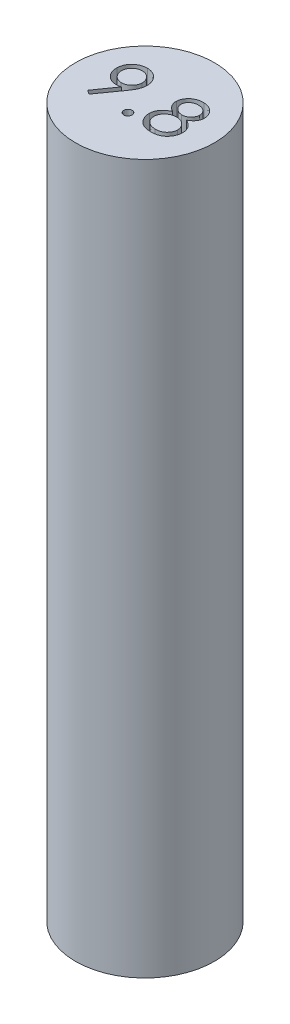
from build123d import *

# Parameters (mm, degrees)
SKETCH1_R           = 4.9
BOSS_EXTRUDE1_DEPTH = 50
CUT_EXTRUDE1_DEPTH  = 3


with BuildPart() as part:
    # Sketch1 → Boss-Extrude1 (new body)
    with BuildSketch(Plane(origin=(0, 0, 0), x_dir=(1, 0, 0), z_dir=(0, 1, 0))):
        Circle(SKETCH1_R)
    extrude(amount=BOSS_EXTRUDE1_DEPTH)

    # Sketch2 → Cut-Extrude1 (cut)
    with BuildSketch(Plane(origin=(0, 50, 0), x_dir=(1, 0, 0), z_dir=(0, 1, 0))):
        with BuildLine():
            Line((-2.497585936, -1.449920869), (-2.778735775, -1.257813497))
            Line((-2.778735775, -1.257813497), (-1.79996975, 0.140924483))
            add(Edge.make_bspline(
                [(-1.79996975, 0.140924483), (-1.831154526, 0.132154323), (-1.891844067, 0.115086476), (-1.9830553, 0.099892479), (-2.070552365, 0.088614887), (-2.128060127, 0.088901517), (-2.156139621, 0.089041471)],
                knots=[0, 0, 0, 0, 9.7102e-05, 0.000188973, 0.000277161, 0.000361308, 0.000361308, 0.000361308, 0.000361308], degree=3))
            add(Edge.make_bspline(
                [(-2.156139621, 0.089041471), (-2.190094119, 0.090939259), (-2.256985081, 0.094677935), (-2.354733317, 0.111790883), (-2.448154149, 0.137987973), (-2.537749058, 0.172862579), (-2.622596718, 0.218357513), (-2.70409283, 0.271705107), (-2.780492641, 0.335419932), (-2.852309599, 0.407025859), (-2.91688194, 0.485644752), (-2.97334181, 0.569004078), (-3.021779134, 0.656136274), (-3.059080726, 0.748188227), (-3.088534655, 0.843835137), (-3.107527163, 0.943763592), (-3.119609821, 1.047642801), (-3.119059029, 1.118254288), (-3.118779846, 1.154045477)],
                knots=[0, 0, 0, 0, 0.000101955, 0.000200853, 0.000296968, 0.000392663, 0.000488634, 0.00058528, 0.000684386, 0.000786515, 0.000889123, 0.000989076, 0.00108823, 0.001187574, 0.001286495, 0.001387971, 0.001492342, 0.001599622, 0.001599622, 0.001599622, 0.001599622], degree=3))
            add(Edge.make_bspline(
                [(-3.118779846, 1.154045477), (-3.115887392, 1.20281857), (-3.110187854, 1.298925234), (-3.079083034, 1.438423427), (-3.032095508, 1.570439215), (-2.967116293, 1.693436969), (-2.88677389, 1.806483918), (-2.790680251, 1.906889445), (-2.681335078, 1.995585706), (-2.558011638, 2.068694131), (-2.42659489, 2.128632766), (-2.288806422, 2.169680659), (-2.147059883, 2.195259224), (-2.05108082, 2.195693218), (-2.002593948, 2.195912464)],
                knots=[0, 0, 0, 0, 0.000146378, 0.000288436, 0.000427048, 0.000565666, 0.000704385, 0.000841757, 0.000981367, 0.001125416, 0.001270712, 0.001413552, 0.001555788, 0.001701003, 0.001701003, 0.001701003, 0.001701003], degree=3))
            add(Edge.make_bspline(
                [(-2.002593948, 2.195912464), (-1.955460082, 2.192983946), (-1.862143465, 2.187186004), (-1.725793063, 2.156131137), (-1.595656952, 2.107901538), (-1.472463357, 2.043636699), (-1.358915451, 1.963881808), (-1.257451639, 1.869746151), (-1.169952541, 1.761592175), (-1.097631411, 1.641146573), (-1.040551758, 1.512695324), (-0.998847689, 1.379269459), (-0.976873152, 1.241270779), (-0.975926851, 1.148272963), (-0.975450519, 1.101461342)],
                knots=[0, 0, 0, 0, 0.000141489, 0.000280124, 0.000417658, 0.000556897, 0.000695783, 0.000832705, 0.000970783, 0.001111707, 0.001252944, 0.001391556, 0.001529991, 0.001670301, 0.001670301, 0.001670301, 0.001670301], degree=3))
            add(Edge.make_bspline(
                [(-0.975450519, 1.101461342), (-0.977559028, 1.065164052), (-0.981841506, 0.991442583), (-1.001582268, 0.879964643), (-1.0318321, 0.766223477), (-1.066324932, 0.670410331), (-1.099914086, 0.591523624), (-1.128930199, 0.528496694), (-1.163915846, 0.463576689), (-1.201654336, 0.394978307), (-1.244590125, 0.323897124), (-1.291212546, 0.249395161), (-1.343725266, 0.173212098), (-1.379751058, 0.121282599), (-1.398226961, 0.094650445)],
                knots=[0, 0, 0, 0, 0.000108999, 0.000221382, 0.000338897, 0.000461755, 0.000526475, 0.000596109, 0.00066981, 0.000747648, 0.000830975, 0.000918895, 0.001011265, 0.001108509, 0.001108509, 0.001108509, 0.001108509], degree=3))
            Line((-1.398226961, 0.094650445), (-2.497585936, -1.449920869))
        make_face()
        with BuildLine():
            add(Edge.make_bspline(
                [(-2.067798275, 0.392627208), (-2.042773915, 0.392642491), (-1.993527934, 0.392672568), (-1.920693864, 0.40051878), (-1.850440852, 0.415195796), (-1.78286431, 0.436803755), (-1.718585096, 0.466200942), (-1.656445661, 0.501334145), (-1.59697847, 0.54333183), (-1.541240244, 0.591822496), (-1.489473698, 0.644313713), (-1.444597365, 0.701528352), (-1.405788709, 0.761328539), (-1.373264599, 0.823886176), (-1.347851047, 0.889482857), (-1.329729292, 0.958181037), (-1.31755772, 1.029780445), (-1.314792777, 1.078744678), (-1.313391224, 1.103564708)],
                knots=[0, 0, 0, 0, 7.5033e-05, 0.000147659, 0.000219301, 0.000290031, 0.00036001, 0.000430972, 0.000503919, 0.000577989, 0.000652361, 0.00072474, 0.000795723, 0.000865965, 0.000935884, 0.001006294, 0.001078794, 0.001153325, 0.001153325, 0.001153325, 0.001153325], degree=3))
            add(Edge.make_bspline(
                [(-1.313391224, 1.103564708), (-1.313424428, 1.128352857), (-1.313490075, 1.177360263), (-1.321113353, 1.249537999), (-1.336190379, 1.319235158), (-1.357535585, 1.386406338), (-1.387003429, 1.450650485), (-1.421879761, 1.512735069), (-1.464340447, 1.571639933), (-1.512554868, 1.627339543), (-1.565082882, 1.679085054), (-1.622302119, 1.723940262), (-1.682224067, 1.762964565), (-1.745380952, 1.795273452), (-1.811655021, 1.82072551), (-1.880838773, 1.838735336), (-1.952874205, 1.851060875), (-2.002077286, 1.853781722), (-2.027133211, 1.855167272)],
                knots=[0, 0, 0, 0, 7.4332e-05, 0.000146958, 0.000217228, 0.000287958, 0.000357937, 0.000428899, 0.000501275, 0.000575345, 0.000649717, 0.000722096, 0.000793079, 0.000863944, 0.000934518, 0.001005604, 0.001078105, 0.001153335, 0.001153335, 0.001153335, 0.001153335], degree=3))
            add(Edge.make_bspline(
                [(-2.027133211, 1.855167272), (-2.051922293, 1.855136711), (-2.100931542, 1.855076291), (-2.173095843, 1.847414917), (-2.242624602, 1.83252438), (-2.309612574, 1.810695072), (-2.374079041, 1.781768998), (-2.436291885, 1.746649386), (-2.495207814, 1.704223751), (-2.550923037, 1.656011418), (-2.602594726, 1.603438967), (-2.64764242, 1.546489088), (-2.685518535, 1.486240002), (-2.718208325, 1.423938569), (-2.743562168, 1.358303477), (-2.761700082, 1.289615692), (-2.773867244, 1.218013447), (-2.776632793, 1.169049605), (-2.778034653, 1.144229772)],
                knots=[0, 0, 0, 0, 7.4332e-05, 0.000146958, 0.000217228, 0.000287291, 0.00035791, 0.000428872, 0.000501248, 0.000575318, 0.00064969, 0.000722069, 0.000792673, 0.000862915, 0.000932834, 0.001003244, 0.001075745, 0.001150275, 0.001150275, 0.001150275, 0.001150275], degree=3))
            add(Edge.make_bspline(
                [(-2.778034653, 1.144229772), (-2.778005458, 1.119440088), (-2.777947738, 1.070429649), (-2.770266683, 0.998274026), (-2.755448173, 0.928713508), (-2.733381182, 0.86193293), (-2.705510455, 0.797104905), (-2.670156894, 0.735098965), (-2.627812036, 0.676142638), (-2.579563516, 0.620461803), (-2.527052601, 0.568694198), (-2.469800322, 0.523906325), (-2.410254274, 0.484813055), (-2.347111117, 0.453548019), (-2.282076967, 0.426834594), (-2.213150477, 0.409040876), (-2.141590762, 0.396773949), (-2.092621072, 0.394022116), (-2.067798275, 0.392627208)],
                knots=[0, 0, 0, 0, 7.4332e-05, 0.000146958, 0.000217228, 0.000287291, 0.000357627, 0.00042859, 0.000500965, 0.000575036, 0.000649407, 0.000721786, 0.000792769, 0.000862692, 0.000932867, 0.001003277, 0.001075778, 0.001150308, 0.001150308, 0.001150308, 0.001150308], degree=3))
        make_face(mode=Mode.SUBTRACT)
        with BuildLine():
            add(Edge.make_bspline(
                [(0.014156577, -0.911918571), (0.033695866, -0.913445512), (0.071934445, -0.916433749), (0.126394001, -0.934724446), (0.175756031, -0.963344534), (0.218838566, -1.001969403), (0.254499553, -1.047749065), (0.280166396, -1.09918911), (0.295849259, -1.155218799), (0.296417208, -1.194132723), (0.296708661, -1.214102065)],
                knots=[0, 0, 0, 0, 5.8614e-05, 0.000114708, 0.000170627, 0.000228735, 0.000287215, 0.000343654, 0.000400289, 0.000459987, 0.000459987, 0.000459987, 0.000459987], degree=3))
            add(Edge.make_bspline(
                [(0.296708661, -1.214102065), (0.295190738, -1.233646533), (0.292220149, -1.271895249), (0.273735984, -1.32647505), (0.245361226, -1.376422202), (0.206691299, -1.419849518), (0.161739718, -1.456832257), (0.110279058, -1.481996743), (0.055073427, -1.497880656), (0.01683865, -1.498461263), (-0.002670346, -1.498757514)],
                knots=[0, 0, 0, 0, 5.8614e-05, 0.000114708, 0.000171234, 0.000229869, 0.000288231, 0.00034467, 0.000400628, 0.000458927, 0.000458927, 0.000458927, 0.000458927], degree=3))
            add(Edge.make_bspline(
                [(-0.002670346, -1.498757514), (-0.022216075, -1.497255983), (-0.060245312, -1.494334524), (-0.114721659, -1.475734472), (-0.16397685, -1.446762211), (-0.207363281, -1.408027233), (-0.243023976, -1.362223726), (-0.268528125, -1.310977135), (-0.284328203, -1.255706588), (-0.284920311, -1.217480716), (-0.285222429, -1.197976264)],
                knots=[0, 0, 0, 0, 5.8614e-05, 0.000114042, 0.00017092, 0.000229028, 0.000287508, 0.000343947, 0.000399905, 0.000458204, 0.000458204, 0.000458204, 0.000458204], degree=3))
            add(Edge.make_bspline(
                [(-0.285222429, -1.197976264), (-0.283655177, -1.178219361), (-0.280570411, -1.139332563), (-0.262775317, -1.083975746), (-0.233603017, -1.034170922), (-0.195242237, -0.990807754), (-0.150243912, -0.953848674), (-0.098795316, -0.928678082), (-0.043586544, -0.912795759), (-0.005352198, -0.912214933), (0.014156577, -0.911918571)],
                knots=[0, 0, 0, 0, 5.931e-05, 0.000116738, 0.000172657, 0.000231291, 0.000289653, 0.000346092, 0.000402051, 0.000460349, 0.000460349, 0.000460349, 0.000460349], degree=3))
        make_face()
        with BuildLine():
            add(Edge.make_bspline(
                [(2.527139212, 0.407363026), (2.555370086, 0.392023612), (2.610273322, 0.36219161), (2.687612583, 0.313186812), (2.759233692, 0.264001654), (2.823986164, 0.212295218), (2.88286337, 0.160212369), (2.935324021, 0.106299529), (2.981805699, 0.051359409), (3.021077203, -0.006208283), (3.055646039, -0.064462006), (3.085352164, -0.12439653), (3.109941341, -0.186304506), (3.129578822, -0.25009495), (3.144135535, -0.315787878), (3.155040538, -0.382925849), (3.159668182, -0.452143975), (3.159590466, -0.498716309), (3.159551071, -0.522324474)],
                knots=[0, 0, 0, 0, 9.636e-05, 0.000187401, 0.000274535, 0.000356877, 0.00043583, 0.000510202, 0.000582377, 0.000651419, 0.000718996, 0.00078547, 0.000851869, 0.000918623, 0.000985469, 0.001053594, 0.001122479, 0.001193295, 0.001193295, 0.001193295, 0.001193295], degree=3))
            add(Edge.make_bspline(
                [(3.159551071, -0.522324474), (3.157777356, -0.555329099), (3.154276884, -0.620464542), (3.139276071, -0.716466855), (3.116175722, -0.809440877), (3.084405838, -0.899200469), (3.045227651, -0.986049031), (2.996852974, -1.068902163), (2.941644151, -1.149589428), (2.898753834, -1.199521795), (2.876998988, -1.224848512)],
                knots=[0, 0, 0, 0, 9.9106e-05, 0.000195589, 0.000290985, 0.000386114, 0.000480869, 0.000576355, 0.000673599, 0.000773693, 0.000773693, 0.000773693, 0.000773693], degree=3))
            add(Edge.make_bspline(
                [(2.876998988, -1.224848512), (2.848677316, -1.254068788), (2.79228215, -1.312253289), (2.69613494, -1.386753143), (2.591458618, -1.448858096), (2.478446553, -1.498844647), (2.357041603, -1.536659202), (2.227594764, -1.562519182), (2.089691662, -1.57575698), (1.995247006, -1.575527557), (1.946610366, -1.57540941)],
                knots=[0, 0, 0, 0, 0.000121963, 0.000242857, 0.00036358, 0.000486309, 0.000612705, 0.000744294, 0.00088166, 0.001027509, 0.001027509, 0.001027509, 0.001027509], degree=3))
            add(Edge.make_bspline(
                [(1.946610366, -1.57540941), (1.899804894, -1.573139311), (1.809106732, -1.568740385), (1.677660078, -1.549673705), (1.55533918, -1.520402515), (1.441812775, -1.48114387), (1.337023047, -1.432168671), (1.241872857, -1.371807837), (1.154635624, -1.302589113), (1.0791621, -1.222102828), (1.012283716, -1.136919116), (0.953988288, -1.04917726), (0.904253531, -0.959915554), (0.864900949, -0.868193139), (0.834677365, -0.774759069), (0.813325761, -0.679528454), (0.801890278, -0.582444442), (0.801749263, -0.517210424), (0.801678475, -0.484463897)],
                knots=[0, 0, 0, 0, 0.00014052, 0.000272296, 0.000397795, 0.000517309, 0.000632096, 0.000743946, 0.000854648, 0.000965232, 0.001074075, 0.001179276, 0.001280949, 0.001380191, 0.001478193, 0.001575153, 0.001672556, 0.001770736, 0.001770736, 0.001770736, 0.001770736], degree=3))
            add(Edge.make_bspline(
                [(0.801678475, -0.484463897), (0.802648831, -0.460587403), (0.804578135, -0.413115081), (0.815066961, -0.343175652), (0.828715283, -0.274888296), (0.847799998, -0.208803287), (0.871584624, -0.144749574), (0.900811727, -0.082966204), (0.933442634, -0.022261777), (0.972271612, 0.036083764), (1.016891781, 0.092293326), (1.066650772, 0.147510933), (1.124034068, 0.200067178), (1.187653946, 0.250916224), (1.257645284, 0.300331024), (1.333967718, 0.347821892), (1.416954567, 0.393425426), (1.475093185, 0.42164136), (1.504903635, 0.43610902)],
                knots=[0, 0, 0, 0, 7.1638e-05, 0.000142434, 0.000211873, 0.000280444, 0.000348554, 0.00041662, 0.000485334, 0.000555144, 0.000626538, 0.000700489, 0.000777886, 0.00085968, 0.000944689, 0.001034764, 0.001129218, 0.001228614, 0.001228614, 0.001228614, 0.001228614], degree=3))
            add(Edge.make_bspline(
                [(1.504903635, 0.43610902), (1.465000232, 0.459693874), (1.387695626, 0.50538466), (1.285573884, 0.587611098), (1.198537577, 0.676276726), (1.128890238, 0.772974465), (1.075037804, 0.874702162), (1.038738739, 0.980784685), (1.015285442, 1.08944377), (1.014508276, 1.163285887), (1.014118379, 1.200331776)],
                knots=[0, 0, 0, 0, 0.000138902, 0.000269093, 0.00039206, 0.000510568, 0.000625349, 0.000735995, 0.000846134, 0.00095702, 0.00095702, 0.00095702, 0.00095702], degree=3))
            add(Edge.make_bspline(
                [(1.014118379, 1.200331776), (1.016913239, 1.238134337), (1.022526056, 1.314051866), (1.052664756, 1.425990864), (1.098988853, 1.535659331), (1.160949986, 1.642289037), (1.238277003, 1.741802502), (1.329132421, 1.831344812), (1.43269032, 1.90868827), (1.547994751, 1.972765818), (1.671348966, 2.024105023), (1.80126765, 2.058861531), (1.93541841, 2.07941735), (2.026231857, 2.079963641), (2.072111167, 2.080239629)],
                knots=[0, 0, 0, 0, 0.000113508, 0.000227954, 0.000345797, 0.000469898, 0.000596818, 0.000722747, 0.000851473, 0.000983314, 0.001117553, 0.001251237, 0.001385889, 0.001523373, 0.001523373, 0.001523373, 0.001523373], degree=3))
            add(Edge.make_bspline(
                [(2.072111167, 2.080239629), (2.116643225, 2.077338605), (2.204578791, 2.071610077), (2.333549901, 2.044353426), (2.456798639, 2.001520261), (2.57309052, 1.942990727), (2.680528934, 1.87228826), (2.77633515, 1.789410751), (2.859298695, 1.695548214), (2.927152046, 1.591044895), (2.981999524, 1.481335786), (3.020332937, 1.367428623), (3.0432216, 1.251287741), (3.044119259, 1.172854954), (3.044567097, 1.133725206)],
                knots=[0, 0, 0, 0, 0.000133745, 0.000264101, 0.000394038, 0.000524162, 0.00065367, 0.000778922, 0.000903117, 0.001028155, 0.001151696, 0.001270092, 0.001387801, 0.001504991, 0.001504991, 0.001504991, 0.001504991], degree=3))
            add(Edge.make_bspline(
                [(3.044567097, 1.133725206), (3.042345852, 1.09521337), (3.037998265, 1.01983513), (3.009609564, 0.910987777), (2.968941438, 0.808231047), (2.910051941, 0.713542302), (2.836851651, 0.625622565), (2.748284662, 0.544780076), (2.644315676, 0.470631861), (2.567138822, 0.428960612), (2.527139212, 0.407363026)],
                knots=[0, 0, 0, 0, 0.000115464, 0.000225995, 0.000335751, 0.000445896, 0.000558916, 0.000678004, 0.000804661, 0.000940933, 0.000940933, 0.000940933, 0.000940933], degree=3))
        make_face()
        with BuildLine():
            add(Edge.make_bspline(
                [(2.045468539, 1.742298924), (2.022082686, 1.742489737), (1.976149098, 1.742864526), (1.908866448, 1.736191144), (1.844313494, 1.725111708), (1.782686457, 1.70849365), (1.724192291, 1.685671005), (1.668358111, 1.65837507), (1.615510269, 1.625209282), (1.566318128, 1.586771951), (1.520999784, 1.545295805), (1.481176704, 1.500728674), (1.447812474, 1.453685391), (1.41893278, 1.405048599), (1.397587019, 1.353645386), (1.381101925, 1.300412907), (1.370445027, 1.244895832), (1.368012838, 1.206919791), (1.366782642, 1.187711584)],
                knots=[0, 0, 0, 0, 7.0116e-05, 0.000137719, 0.000202499, 0.000266451, 0.00032882, 0.00039059, 0.000452646, 0.000515615, 0.000577635, 0.000636734, 0.00069452, 0.000750438, 0.000806044, 0.000861045, 0.000917424, 0.000975125, 0.000975125, 0.000975125, 0.000975125], degree=3))
            add(Edge.make_bspline(
                [(1.366782642, 1.187711584), (1.366704781, 1.168507037), (1.366550132, 1.130362371), (1.375999697, 1.073857727), (1.389202963, 1.01823834), (1.411264508, 0.964652784), (1.437718224, 0.911438579), (1.471538292, 0.860037946), (1.511329284, 0.809520281), (1.557064324, 0.761440052), (1.606610599, 0.716152718), (1.659863001, 0.676905817), (1.714435154, 0.641954597), (1.77213132, 0.613883668), (1.832264266, 0.5923948), (1.893988226, 0.575128809), (1.958427036, 0.564570633), (2.002196513, 0.562142423), (2.024434885, 0.560908699)],
                knots=[0, 0, 0, 0, 5.7509e-05, 0.000114226, 0.000171362, 0.000228649, 0.000287597, 0.000349439, 0.000412839, 0.000480293, 0.000548302, 0.000613927, 0.00067851, 0.000742478, 0.000805913, 0.000869865, 0.000934528, 0.001001315, 0.001001315, 0.001001315, 0.001001315], degree=3))
            add(Edge.make_bspline(
                [(2.024434885, 0.560908699), (2.05301569, 0.560988033), (2.10961942, 0.561145151), (2.193316996, 0.576480889), (2.275303122, 0.599862924), (2.354132124, 0.635114343), (2.42796287, 0.679478332), (2.49448909, 0.732471659), (2.552873879, 0.79332604), (2.601069762, 0.861951792), (2.641131946, 0.933975563), (2.669852301, 1.008124683), (2.689178779, 1.082540319), (2.692873661, 1.13268035), (2.694707321, 1.157563347)],
                knots=[0, 0, 0, 0, 8.5583e-05, 0.000169495, 0.000254247, 0.000340883, 0.000427697, 0.00051201, 0.000595323, 0.000679761, 0.000762911, 0.000841942, 0.000917783, 0.000992501, 0.000992501, 0.000992501, 0.000992501], degree=3))
            add(Edge.make_bspline(
                [(2.694707321, 1.157563347), (2.694585692, 1.175108637), (2.694344822, 1.209854525), (2.687890054, 1.261596955), (2.675914461, 1.312374007), (2.658224693, 1.362068409), (2.635607777, 1.410969746), (2.607366836, 1.458841008), (2.573344033, 1.50558434), (2.535499449, 1.552054893), (2.491289121, 1.594313201), (2.44293305, 1.633096545), (2.388264587, 1.664101572), (2.329501278, 1.691155312), (2.265707845, 1.713054495), (2.196452137, 1.72785465), (2.122681912, 1.738840152), (2.071685455, 1.741124537), (2.045468539, 1.742298924)],
                knots=[0, 0, 0, 0, 5.2603e-05, 0.000104172, 0.000156041, 0.000208816, 0.000262143, 0.000317456, 0.000375243, 0.000435478, 0.000496961, 0.000558392, 0.000620922, 0.000684924, 0.000752327, 0.000822747, 0.000897112, 0.000975791, 0.000975791, 0.000975791, 0.000975791], degree=3))
        make_face(mode=Mode.SUBTRACT)
        with BuildLine():
            add(Edge.make_bspline(
                [(2.020929276, 0.246105013), (1.991465526, 0.246135445), (1.933571999, 0.246195239), (1.848313244, 0.237763254), (1.76668215, 0.221506049), (1.688183432, 0.198317112), (1.613037043, 0.167666769), (1.541813636, 0.128375309), (1.473596391, 0.082854871), (1.409685811, 0.030545), (1.35118959, -0.026396148), (1.299583384, -0.086845956), (1.255974869, -0.150455821), (1.219118906, -0.21613538), (1.190990136, -0.28504963), (1.170024102, -0.356213742), (1.155191581, -0.430124916), (1.152765027, -0.480653348), (1.151538251, -0.506198673)],
                knots=[0, 0, 0, 0, 8.8352e-05, 0.000173604, 0.000256518, 0.000337709, 0.000418824, 0.000499456, 0.000581322, 0.000664544, 0.000746847, 0.000825937, 0.000902562, 0.000977879, 0.001051444, 0.001125315, 0.001200256, 0.001276884, 0.001276884, 0.001276884, 0.001276884], degree=3))
            add(Edge.make_bspline(
                [(1.151538251, -0.506198673), (1.151665229, -0.537841466), (1.151918486, -0.600952318), (1.170942782, -0.693964971), (1.200268698, -0.785262604), (1.243713788, -0.872736352), (1.298703523, -0.954480438), (1.364819551, -1.027925358), (1.441923917, -1.091308437), (1.529329126, -1.144639487), (1.626083825, -1.187332096), (1.730715696, -1.219583821), (1.843256919, -1.240150318), (1.920816779, -1.244401108), (1.960632802, -1.246583288)],
                knots=[0, 0, 0, 0, 9.4716e-05, 0.00018891, 0.000283361, 0.000381818, 0.000480798, 0.000578095, 0.000677201, 0.000779171, 0.000884315, 0.000993648, 0.001106965, 0.001226504, 0.001226504, 0.001226504, 0.001226504], degree=3))
            add(Edge.make_bspline(
                [(1.960632802, -1.246583288), (1.991500776, -1.246928174), (2.051966112, -1.247603749), (2.140415569, -1.238818141), (2.224415061, -1.223481846), (2.303700667, -1.201340916), (2.37805007, -1.171433218), (2.448009118, -1.135170167), (2.512717582, -1.090336817), (2.572721654, -1.039689154), (2.625989964, -0.983433059), (2.674453817, -0.92560146), (2.714341499, -0.863788152), (2.748445059, -0.800283853), (2.774305199, -0.733487457), (2.79415282, -0.664575336), (2.807014739, -0.592885505), (2.80972646, -0.544109682), (2.811093539, -0.519519987)],
                knots=[0, 0, 0, 0, 9.2551e-05, 0.000181292, 0.000266139, 0.000348481, 0.00042777, 0.000506174, 0.000584351, 0.000663441, 0.000741291, 0.00081652, 0.000889444, 0.000961578, 0.001032405, 0.001103864, 0.001176484, 0.001250315, 0.001250315, 0.001250315, 0.001250315], degree=3))
            add(Edge.make_bspline(
                [(2.811093539, -0.519519987), (2.811176718, -0.495654923), (2.811342116, -0.448200394), (2.801810419, -0.377621838), (2.784949107, -0.309071273), (2.761101667, -0.242008894), (2.728023263, -0.177871299), (2.689854303, -0.113935402), (2.642225537, -0.053297149), (2.588750388, 0.00528553), (2.529887579, 0.059283842), (2.467203517, 0.107477179), (2.400946503, 0.148324907), (2.331206781, 0.182245902), (2.257966669, 0.208585072), (2.181918009, 0.229433788), (2.102419796, 0.242003954), (2.04831451, 0.244726835), (2.020929276, 0.246105013)],
                knots=[0, 0, 0, 0, 7.1528e-05, 0.00014223, 0.000212971, 0.000283055, 0.000355172, 0.000429122, 0.000506112, 0.000586006, 0.000666891, 0.000745419, 0.000822861, 0.0009, 0.000977632, 0.001056035, 0.001136261, 0.001218484, 0.001218484, 0.001218484, 0.001218484], degree=3))
        make_face(mode=Mode.SUBTRACT)
    extrude(amount=-CUT_EXTRUDE1_DEPTH, mode=Mode.SUBTRACT)


solid = part.part
